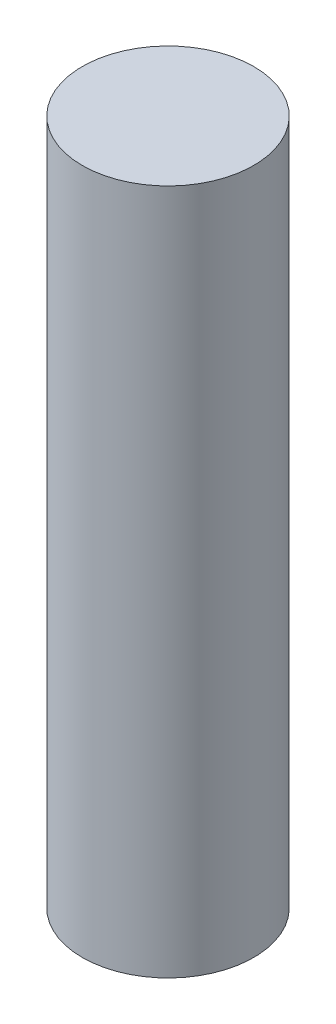
from build123d import *

# Parameters (mm, degrees)
SKETCH1_R           = 20
BOSS_EXTRUDE1_DEPTH = 160


with BuildPart() as part:
    # Sketch1 → Boss-Extrude1 (new body)
    with BuildSketch(Plane(origin=(0, 0, 0), x_dir=(1, 0, 0), z_dir=(0, 1, 0))):
        Circle(SKETCH1_R)
    extrude(amount=BOSS_EXTRUDE1_DEPTH)


solid = part.part
